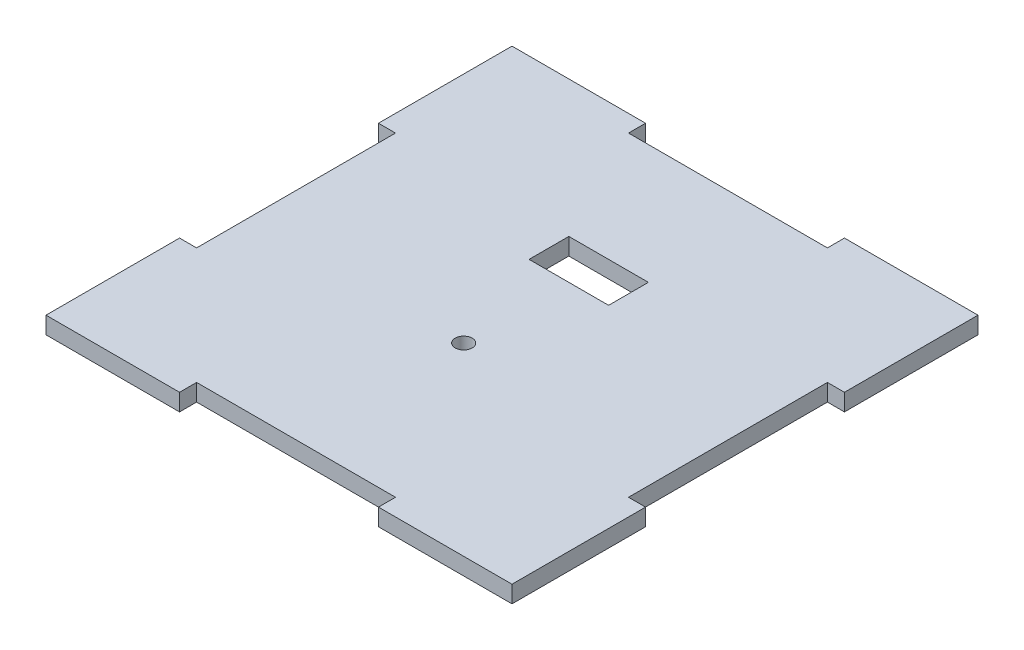
from build123d import *

# Parameters (mm, degrees)
BOSS_EXTRUDE1_DEPTH = 3
SKETCH2_R           = 1.5
SKETCH2_W           = 14
SKETCH2_H           = 7
CUT_EXTRUDE1_DEPTH  = 3


with BuildPart() as part:
    # Sketch1 → Boss-Extrude1 (new body)
    with BuildSketch(Plane(origin=(0, 0, 0), x_dir=(1, 0, 0), z_dir=(0, 1, 0))):
        Polygon((-41, -41), (-17.5, -41), (-17.5, -38), (17.5, -38), (17.5, -41), (41, -41), (41, -17.5), (38, -17.5), (38, 17.5), (41, 17.5), (41, 41), (17.5, 41), (17.5, 38), (-17.5, 38), (-17.5, 41), (-41, 41), (-41, 17.5), (-38, 17.5), (-38, -17.5), (-41, -17.5), align=None)
    extrude(amount=BOSS_EXTRUDE1_DEPTH)

    # Sketch2 → Cut-Extrude1 (cut)
    with BuildSketch(Plane(origin=(0, 3, 0), x_dir=(1, 0, 0), z_dir=(0, 1, 0))):
        with Locations((0, -8.5)):
            Circle(SKETCH2_R)
        with Locations((0, 13.5)):
            Rectangle(SKETCH2_W, SKETCH2_H)
    extrude(amount=-CUT_EXTRUDE1_DEPTH, mode=Mode.SUBTRACT)


solid = part.part
